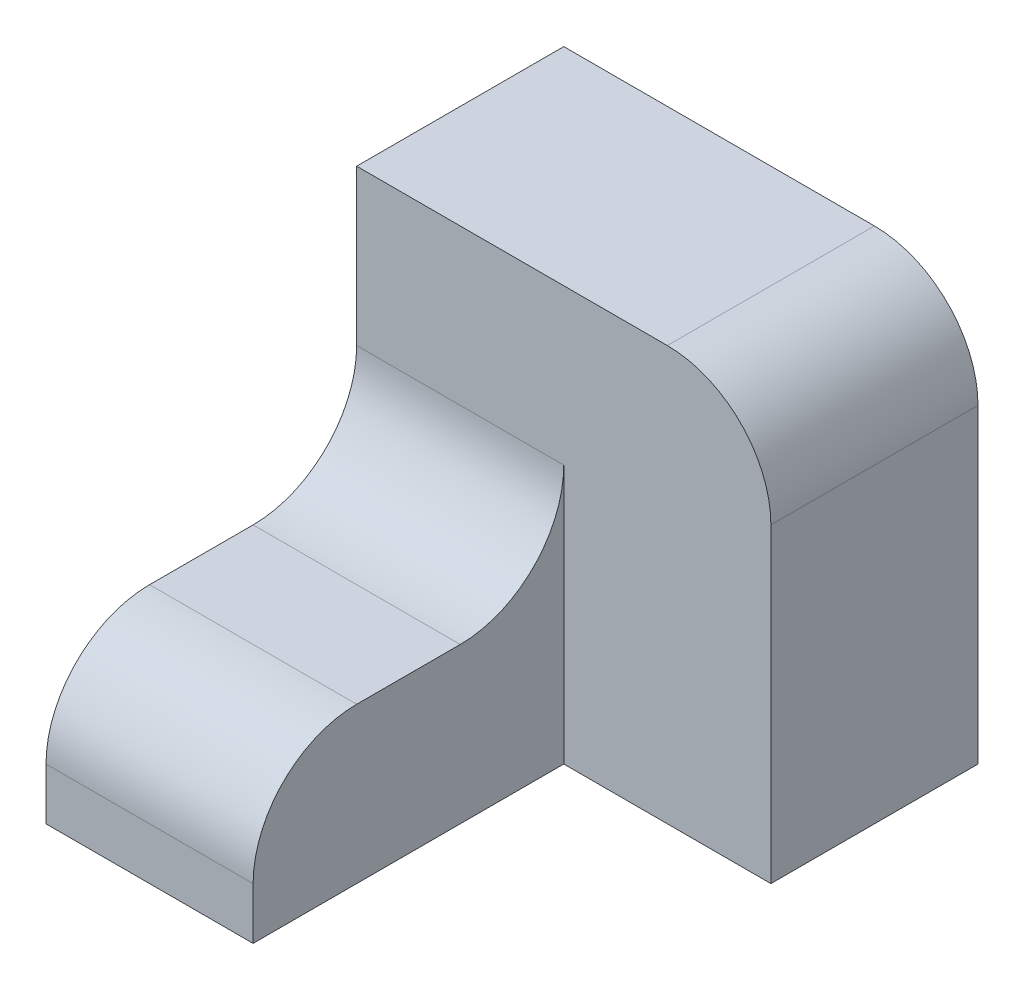
from build123d import *

# Parameters (mm, degrees)
SKETCH1_W           = 20
SKETCH1_H           = 15
BOSS_EXTRUDE1_DEPTH = 30
SKETCH2_W           = 40
SKETCH2_H           = 40
BOSS_EXTRUDE2_DEPTH = 20
FILLET1_R           = 10


with BuildPart() as part:
    # Sketch1 → Boss-Extrude1 (new body)
    with BuildSketch(Plane.XY):
        with Locations((-20, -7.5)):
            Rectangle(SKETCH1_W, SKETCH1_H)
    extrude(amount=BOSS_EXTRUDE1_DEPTH)

    # Sketch2 → Boss-Extrude2 (add)
    with BuildSketch(Plane.XY):
        with Locations((-10, 5)):
            Rectangle(SKETCH2_W, SKETCH2_H)
    extrude(amount=-BOSS_EXTRUDE2_DEPTH)

    # Fillet1
    fillet1_edges = [part.edges().sort_by_distance(p)[0] for p in [
        (10, 25, -10),
        (-20, 0, 30),
        (-20, 0, 0),
    ]]
    fillet(fillet1_edges, radius=FILLET1_R)


solid = part.part
